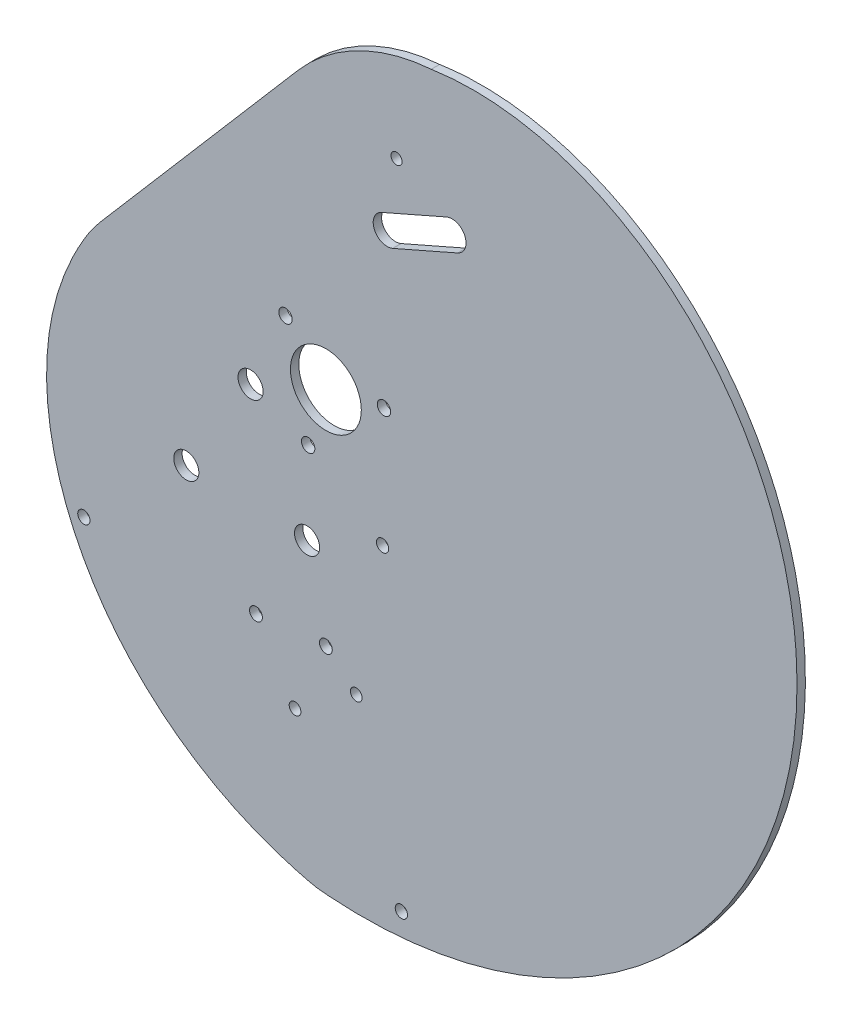
from build123d import *

# Parameters (mm, degrees)
SKETCH1_R               = 6.35
BOSS_EXTRUDE1_DEPTH     = 0.75
CUT_EXTRUDE1_DEPTH      = 102.161590478
CUT_EXTRUDE1_DEPTH_BACK = 102.161590478
FILLET1_R               = 20
BOSS_EXTRUDE2_DEPTH     = 0.75
SKETCH7_R               = 6.35
SKETCH7_R_2             = 3.175
BOSS_EXTRUDE3_DEPTH     = 0.75
SKETCH8_R               = 1
SKETCH8_R_2             = 6.35
CUT_EXTRUDE2_DEPTH      = 116.292862823
CUT_EXTRUDE2_DEPTH_BACK = 116.292862823
M4_CLEARANCE_HOLE1_D    = 4.5
M2_CLEARANCE_HOLE1_D    = 2.4
SKETCH15_R              = 1.1
CUT_EXTRUDE3_DEPTH      = 10
SKETCH16_R              = 1.05
SKETCH16_R_2            = 1.1
CUT_EXTRUDE4_DEPTH      = 116.300180911
SKETCH18_R              = 1.15
CUT_EXTRUDE5_DEPTH      = 116.300180911


with BuildPart() as part:
    # Sketch1 → Boss-Extrude1 (new, symmetric)
    with BuildSketch(Plane.XY):
        with BuildLine():
            ThreePointArc((11.984914181, 27.895733584), (8.691133377, 29.180649151), (9.976048944, 32.474429955))
            Line((9.976048944, 32.474429955), (12.234616167, 33.46535768))
            ThreePointArc((12.234616167, 33.46535768), (8.26006825, 34.969173712), (5.615201844, 38.295308932))
            Line((5.615201844, 38.295308932), (3.856119442, 42.419673356))
            add(Edge.make_bspline(
                [(3.856119442, 42.419673356), (3.804269194, 42.380475154), (3.486745937, 42.138972836), (2.912619563, 41.685826384), (2.149082762, 41.044776761), (1.408732666, 40.385653153), (0.69201842, 39.710962437), (-0.000702823, 39.023274092), (-0.669224606, 38.325164066), (-1.313490613, 37.619209289), (-1.933594741, 36.907981167), (-2.529780734, 36.194039342), (-3.102441662, 35.479925366), (-3.652119172, 34.768156406), (-4.179502537, 34.061218936), (-4.68542751, 33.361562432), (-5.170874981, 32.671593072), (-5.636969475, 31.993667421), (-6.084977486, 31.330086125), (-6.5163057, 30.68308757), (-6.932499191, 30.054841594), (-7.335239472, 29.447442991), (-7.726343211, 28.862905788), (-8.107759261, 28.30315506), (-8.481572996, 27.770028153), (-8.850055929, 27.265150233), (-9.21599154, 26.789707359), (-9.58007402, 26.342396401), (-9.943199031, 25.921274986), (-10.306211946, 25.524302901), (-10.669815304, 25.149428396), (-11.03457423, 24.794597749), (-11.400917427, 24.457759077), (-11.769139802, 24.136868148), (-12.139404915, 23.829894257), (-12.511747444, 23.534826559), (-12.886075425, 23.249680558), (-13.262172288, 22.972504592), (-13.639698706, 22.701386132), (-14.018194373, 22.4344578), (-14.397079826, 22.169903041), (-14.775658393, 21.905961469), (-15.153118349, 21.640933911), (-15.528535328, 21.37318718), (-15.900874865, 21.101158728), (-16.268995598, 20.823360748), (-16.631651048, 20.538385549), (-16.987497448, 20.244905703), (-17.335071725, 19.941700072), (-17.674482118, 19.629485326), (-18.005889299, 19.308945872), (-18.329486913, 18.98074786), (-18.645506177, 18.6455329), (-18.954213469, 18.303917657), (-19.255909475, 17.956492143), (-19.550927855, 17.603818409), (-19.839633983, 17.246429189), (-20.122423608, 16.884826615), (-20.39972148, 16.519480973), (-20.671979932, 16.15082951), (-20.93967742, 15.77927529), (-21.203317027, 15.405186109), (-21.463424922, 15.028893458), (-21.720548787, 14.650691546), (-21.975256201, 14.270836377), (-22.228133, 13.889544888), (-22.479781587, 13.506994147), (-22.730819224, 13.123320602), (-22.981876279, 12.738619403), (-23.233594452, 12.35294377), (-23.486624965, 11.966304432), (-23.741626724, 11.578669117), (-23.999264462, 11.189962103), (-24.260206854, 10.800063825), (-24.52512461, 10.408810538), (-24.794688561, 10.015994037), (-25.069567717, 9.621361426), (-25.350427363, 9.224614974), (-25.637926993, 8.8254119), (-25.932718851, 8.423364715), (-26.235444149, 8.018039723), (-26.546738212, 7.608962846), (-26.867193334, 7.195608336), (-27.197393741, 6.777566684), (-27.537037782, 6.353934602), (-27.885559202, 5.923803469), (-28.242374703, 5.486366009), (-28.606855737, 5.040842301), (-28.978345064, 4.586492757), (-29.356154138, 4.122615768), (-29.739565815, 3.648549546), (-30.127835637, 3.163672741), (-30.520193566, 2.667405334), (-30.915845631, 2.159209384), (-31.313975642, 1.638589743), (-31.713746908, 1.10509472), (-32.114303997, 0.558316687), (-32.514774496, -0.002107372), (-32.914270801, -0.576495363), (-33.311891916, -1.165119646), (-33.70672526, -1.768206653), (-34.097848491, -2.385936568), (-34.484331334, -3.01844306), (-34.865237414, -3.665813085), (-35.239626095, -4.328086735), (-35.606554319, -5.00525716), (-35.965078448, -5.697270543), (-36.314256102, -6.404026134), (-36.653147994, -7.125376348), (-36.98081976, -7.861126926), (-37.296343783, -8.611037148), (-37.598801011, -9.374820113), (-37.887282738, -10.15214308), (-38.160892488, -10.942627847), (-38.418747446, -11.745851279), (-38.659981522, -12.561345551), (-38.883742182, -13.388599746), (-39.089211497, -14.227059816), (-39.27554787, -15.076191303), (-39.442240692, -15.935443066), (-39.58900499, -16.804297383), (-39.715531283, -17.682274795), (-39.821534024, -18.56888584), (-39.906736403, -19.463633732), (-39.970874682, -20.366013757), (-40.01369729, -21.27551381), (-40.034965324, -22.191614638), (-40.034452659, -23.113790166), (-40.011946156, -24.041507803), (-39.967245835, -24.974228766), (-39.900165044, -25.911408403), (-39.810530622, -26.852496518), (-39.698183052, -27.796937709), (-39.56297661, -28.744171699), (-39.4047795, -29.693633681), (-39.223473982, -30.64475466), (-39.018956498, -31.596961802), (-38.791137779, -32.549678783), (-38.539942955, -33.502326148), (-38.265311644, -34.454321664), (-37.967198044, -35.405080681), (-37.645571006, -36.354016496), (-37.300414107, -37.300540716), (-36.931725709, -38.244063627), (-36.539519007, -39.18399456), (-36.123822074, -40.119742265), (-35.684677893, -41.050715279), (-35.222144381, -41.976322302), (-34.736294403, -42.89597257), (-34.227215775, -43.809076229), (-33.695011264, -44.715044715), (-33.139798572, -45.613291121), (-32.561710315, -46.503230581), (-31.960893988, -47.384280643), (-31.337511928, -48.255861642), (-30.69174126, -49.117397078), (-30.023773839, -49.96831399), (-29.333816181, -50.808043326), (-28.622089382, -51.636020317), (-27.888829033, -52.451684847), (-27.134285123, -53.25448182), (-26.358721931, -54.04386153), (-25.562417912, -54.819280022), (-24.745665571, -55.580199454), (-23.908771332, -56.326088459), (-23.052055394, -57.0564225), (-22.175851579, -57.770684224), (-21.280507172, -58.468363812), (-20.366382752, -59.148959324), (-19.433852012, -59.811977048), (-18.483301577, -60.456931829), (-17.515130802, -61.083347415), (-16.529751575, -61.690756781), (-15.527588097, -62.278702456), (-14.50907667, -62.846736843), (-13.474665463, -63.39442255), (-12.424814268, -63.921332635), (-11.359994294, -64.427051169), (-10.280687768, -64.911172569), (-9.187388219, -65.373305515), (-8.080598179, -65.813059652), (-6.960836498, -66.230096831), (-5.828609627, -66.623940268), (-4.684517934, -66.994691537), (-3.528855652, -67.340343195), (-2.3631095, -67.666856553), (-1.184338477, -67.950378607), (-0.400093515, -68.169065005), (0, -68.230921715)],
                knots=[0.595074645, 0.595074645, 0.595074645, 0.595074645, 0.59561552, 0.598394199, 0.601160164, 0.603910525, 0.606641733, 0.609350191, 0.612032273, 0.614684334, 0.617302722, 0.619883791, 0.622423916, 0.624919509, 0.627367038, 0.629763043, 0.632104166, 0.634387177, 0.636609005, 0.638766786, 0.640857908, 0.642880081, 0.644831406, 0.646710483, 0.648516525, 0.650249514, 0.65191136, 0.653508519, 0.655048349, 0.65653798, 0.657984241, 0.659393583, 0.66077201, 0.662125022, 0.663457568, 0.664774018, 0.666078151, 0.667373165, 0.668661696, 0.669945853, 0.671227263, 0.672507127, 0.673786273, 0.67506522, 0.676344239, 0.677623416, 0.678902717, 0.68018205, 0.681461324, 0.682740438, 0.684019262, 0.685297659, 0.686575488, 0.687852615, 0.689128915, 0.690404281, 0.691678632, 0.692951916, 0.694224122, 0.695495279, 0.696765474, 0.698034846, 0.699303605, 0.70057203, 0.70184048, 0.703109399, 0.704379325, 0.705650892, 0.706924838, 0.708202013, 0.709483377, 0.710770009, 0.712063109, 0.713363997, 0.714674119, 0.715995039, 0.717328447, 0.718676146, 0.720040056, 0.721422204, 0.722824718, 0.724249822, 0.725699824, 0.727177002, 0.72868281, 0.730218172, 0.731783831, 0.733380363, 0.735008197, 0.736667628, 0.738358831, 0.740081872, 0.741836722, 0.743623264, 0.745441305, 0.747290584, 0.749170776, 0.751081502, 0.753022336, 0.754992805, 0.756992401, 0.759020578, 0.761076761, 0.763160347, 0.76527071, 0.767407202, 0.769569155, 0.771755887, 0.7739667, 0.776200882, 0.778457713, 0.780736462, 0.783036392, 0.785356757, 0.787696808, 0.790055792, 0.792432952, 0.794827532, 0.797238799, 0.799666426, 0.802110394, 0.804570687, 0.807047284, 0.809540165, 0.812049305, 0.814574675, 0.817116246, 0.819673984, 0.822247852, 0.824837811, 0.82744382, 0.830065834, 0.832703806, 0.835357687, 0.838027424, 0.840712962, 0.843414244, 0.84613121, 0.848863798, 0.851611942, 0.854375576, 0.857154631, 0.859949033, 0.862758708, 0.865583582, 0.868423573, 0.871278601, 0.874148584, 0.877033434, 0.879933066, 0.882847387, 0.885776307, 0.888719732, 0.891677564, 0.894649707, 0.897636058, 0.900636516, 0.903650977, 0.906679333, 0.909721476, 0.912777297, 0.915846682, 0.918929518, 0.922025687, 0.925135072, 0.928257554, 0.931393009, 0.934541315, 0.937702347, 0.940875975, 0.944062073, 0.947260508, 0.950471149, 0.95369386, 0.956928506, 0.960174949, 0.96343305, 0.966702667, 0.969983657, 0.973275876, 0.976579178, 0.979893415, 0.983218438, 0.986554095, 0.989900235, 0.993256703, 0.996623344, 1, 1, 1, 1], degree=3))
            add(Edge.make_bspline(
                [(0, -68.230921715), (0.393333706, -68.291733321), (1.194961176, -68.321276753), (2.388868431, -68.414811628), (3.58891617, -68.470136134), (4.791044831, -68.510535556), (5.995946289, -68.52954927), (7.203026535, -68.528713614), (8.412027616, -68.507423129), (9.62259203, -68.465654591), (10.83437986, -68.403235569), (12.047037443, -68.320041284), (13.260205927, -68.215942066), (14.473519127, -68.090817818), (15.686604264, -67.944554476), (16.899081946, -67.777045295), (18.110566359, -67.588190842), (19.320665416, -67.377899329), (20.528980925, -67.146086849), (21.73510877, -66.892677633), (22.938639087, -66.6176043), (24.139156466, -66.320808097), (25.336240146, -66.002239142), (26.529464226, -65.661856654), (27.718397887, -65.299629187), (28.90260561, -64.915534847), (30.081647414, -64.509561514), (31.255079097, -64.081707052), (32.42245248, -63.631979515), (33.58331567, -63.160397343), (34.737213315, -62.666989561), (35.883686879, -62.151795956), (37.022274916, -61.614867262), (38.152513354, -61.056265327), (39.273935784, -60.476063279), (40.386073758, -59.87434568), (41.488457085, -59.251208675), (42.580614147, -58.606760131), (43.662072205, -57.941119771), (44.732357722, -57.254419292), (45.790996682, -56.546802486), (46.837514925, -55.81842534), (47.871438475, -55.069456136), (48.89229388, -54.300075538), (49.899608554, -53.51047667), (50.892911122, -52.700865183), (51.871731772, -51.87145932), (52.835602603, -51.022489959), (53.784057989, -50.154200657), (54.71663493, -49.26684768), (55.632873421, -48.360700021), (56.532316811, -47.436039411), (57.414512174, -46.493160317), (58.279010671, -45.532369935), (59.125367928, -44.553988165), (59.953144401, -43.558347582), (60.761905749, -42.545793391), (61.55122321, -41.516683378), (62.320673971, -40.471387842), (63.069841543, -39.410289525), (63.798316132, -38.333783527), (64.505695017, -37.242277204), (65.191582915, -36.13619007), (65.85559236, -35.015953676), (66.497344063, -33.882011479), (67.11646729, -32.734818707), (67.71260022, -31.574842209), (68.285390316, -30.402560293), (68.834494677, -29.218462553), (69.359580408, -28.023049692), (69.860324965, -26.816833323), (70.336416512, -25.60033577), (70.787554269, -24.374089852), (71.213448854, -23.13863866), (71.613822626, -21.894535318), (71.988410015, -20.642342743), (72.336957858, -19.382633384), (72.659225719, -18.115988959), (72.954986211, -16.843000179), (73.224025309, -15.564266461), (73.466142659, -14.28039563), (73.681151874, -12.992003617), (73.868880836, -11.699714142), (74.029171977, -10.404158388), (74.161882563, -9.10597467), (74.266884966, -7.805808087), (74.344066927, -6.504310174), (74.393331816, -5.202138538), (74.414598879, -3.89995649), (74.407803478, -2.598432666), (74.372897323, -1.29824064), (74.309848696, -5.853e-05), (74.218642658, 1.295431404), (74.099281259, 2.587543173), (73.95178373, 3.875587471), (73.776186663, 5.158872107), (73.572544188, 6.43670243), (73.340928136, 7.708381771), (73.081428188, 8.973211889), (72.794152019, 10.230493418), (72.47922543, 11.479526328), (72.13679246, 12.719610386), (71.767015501, 13.950045625), (71.37007539, 15.170132817), (70.946171493, 16.379173951), (70.495521777, 17.576472716), (70.018362872, 18.761334989), (69.514950114, 19.933069325), (68.985557583, 21.090987453), (68.430478125, 22.234404772), (67.850023359, 23.362640855), (67.244523678, 24.47501995), (66.614328227, 25.570871489), (65.959804877, 26.649530597), (65.281340181, 27.710338599), (64.579339317, 28.752643533), (63.85422602, 29.775800665), (63.106442497, 30.779173), (62.33644933, 31.762131799), (61.544725366, 32.724057086), (60.731767601, 33.66433818), (59.898090995, 34.582374149), (59.044228508, 35.477574541), (58.170730235, 36.349359075), (57.278166357, 37.197160694), (56.367121668, 38.020410915), (55.438270074, 38.818621759), (54.492318121, 39.591335254), (53.529982536, 40.3381068), (52.551992493, 41.058512637), (51.559087829, 41.752148676), (50.552018856, 42.418631155), (49.531545735, 43.057596786), (48.498437965, 43.668703015), (47.453473832, 44.251628246), (46.397439863, 44.806072049), (45.331130274, 45.331755356), (44.255346411, 45.828420647), (43.17089619, 46.295832116), (42.078593533, 46.733775825), (40.979257798, 47.142059848), (39.873713209, 47.520514394), (38.762788284, 47.868991924), (37.647315256, 48.187367242), (36.528129497, 48.475537585), (35.406068937, 48.733422689), (34.281973488, 48.960964845), (33.156684455, 49.158128938), (32.031043959, 49.324902476), (30.905894352, 49.461295599), (29.78207764, 49.567341079), (28.66043489, 49.643094299), (27.541805663, 49.688633226), (26.427027423, 49.704058363), (25.316934962, 49.689492689), (24.212359828, 49.645081585), (23.114129743, 49.570992746), (22.023068037, 49.46741608), (20.939993076, 49.334563587), (19.865717696, 49.172669234), (19.050939925, 49.026743912), (18.594215776, 48.936446476), (18.491236259, 48.915651329)],
                knots=[0, 0, 0, 0, 0.003319606, 0.00664483, 0.00997572, 0.013312315, 0.016654652, 0.020002764, 0.023356679, 0.026716422, 0.030082012, 0.033453467, 0.036830797, 0.040214011, 0.043603114, 0.046998106, 0.050398984, 0.05380574, 0.057218364, 0.060636841, 0.064061153, 0.067491279, 0.070927192, 0.074368865, 0.077816264, 0.081269354, 0.084728096, 0.088192446, 0.09166236, 0.095137787, 0.098618675, 0.102104968, 0.105596607, 0.10909353, 0.112595671, 0.116102963, 0.119615332, 0.123132706, 0.126655005, 0.130182149, 0.133714056, 0.137250637, 0.140791804, 0.144337465, 0.147887524, 0.151441884, 0.155000443, 0.158563099, 0.162129745, 0.165700272, 0.169274569, 0.172852522, 0.176434014, 0.180018926, 0.183607137, 0.187198521, 0.190792953, 0.194390304, 0.197990441, 0.201593231, 0.205198539, 0.208806224, 0.212416148, 0.216028167, 0.219642135, 0.223257906, 0.226875331, 0.230494258, 0.234114533, 0.237736001, 0.241358506, 0.244981886, 0.248605983, 0.252230632, 0.255855669, 0.259480928, 0.263106241, 0.266731437, 0.270356345, 0.273980794, 0.277604607, 0.281227611, 0.284849627, 0.288470478, 0.292089983, 0.295707963, 0.299324234, 0.302938615, 0.306550921, 0.310160967, 0.313768569, 0.317373538, 0.320975689, 0.324574833, 0.328170782, 0.331763348, 0.335352341, 0.338937573, 0.342518853, 0.346095993, 0.349668803, 0.353237093, 0.356800674, 0.360359359, 0.363912958, 0.367461284, 0.37100415, 0.37454137, 0.37807276, 0.381598135, 0.385117313, 0.388630113, 0.392136355, 0.395635862, 0.399128458, 0.402613969, 0.406092224, 0.409563054, 0.413026294, 0.416481778, 0.419929348, 0.423368847, 0.426800121, 0.43022302, 0.4336374, 0.437043112, 0.440439966, 0.443827754, 0.447206268, 0.450575308, 0.453934675, 0.457284173, 0.460623612, 0.463952804, 0.467271567, 0.470579721, 0.473877092, 0.477163509, 0.480438807, 0.483702825, 0.486955407, 0.490196401, 0.493425661, 0.496643048, 0.499848424, 0.50304166, 0.506222633, 0.509391223, 0.512547319, 0.515690814, 0.518821608, 0.521939609, 0.52504473, 0.528136891, 0.531216019, 0.53428205, 0.537334925, 0.540374595, 0.543401017, 0.546414157, 0.549413988, 0.550288202, 0.550288202, 0.550288202, 0.550288202], degree=3))
            Line((18.491236259, 48.915651329), (20.341962163, 44.576418519))
            ThreePointArc((20.341962163, 44.576418519), (20.922430656, 40.447066292), (19.347370503, 36.586019931))
            Line((19.347370503, 36.586019931), (21.605937727, 37.576947657))
            ThreePointArc((21.605937727, 37.576947657), (24.899718531, 36.29203209), (23.614802964, 32.998251286))
            Line((23.614802964, 32.998251286), (11.984914181, 27.895733584))
        make_face()
        Circle(SKETCH1_R, mode=Mode.SUBTRACT)
    extrude(amount=BOSS_EXTRUDE1_DEPTH, both=True)

    # Sketch2 → Cut-Extrude1 (cut, two sides)
    with BuildSketch(Plane.XY) as cut_extrude1_sk:
        Polygon((-35.700141367, -3.650772794), (-7.072677907, 43.311946145), (4.622228263, 43.311946145), (7.657062795, 40.706225638), (-41.200196706, -16.19692185), align=None)
    extrude(amount=CUT_EXTRUDE1_DEPTH, mode=Mode.SUBTRACT)
    extrude(cut_extrude1_sk.sketch, amount=-CUT_EXTRUDE1_DEPTH_BACK, mode=Mode.SUBTRACT)

    # Fillet1
    fillet1_edges = [part.edges().sort_by_distance(p)[0] for p in [
        (-38.918855467, -13.539885857, -0.3749997),
    ]]
    fillet(fillet1_edges, radius=FILLET1_R)

    # Sketch6 → Boss-Extrude2 (add, symmetric)
    with BuildSketch(Plane.XY):
        with BuildLine():
            Line((-40.240877686, 5.985028621), (-5.010941183, 47.016684781))
            ThreePointArc((-5.010941183, 47.016684781), (5.728997706, 55.445724795), (18.87378975, 59.134822925))
            add(Edge.make_bspline(
                [(18.87378975, 59.134822925), (22.516816499, 59.686781934), (26.193665623, 59.826089241), (33.45068059, 59.346128102), (37.03127521, 58.727162925), (43.967380955, 56.811462619), (47.322941455, 55.514954983), (53.707777021, 52.33122275), (56.737127918, 50.44408812), (62.389510018, 46.169164114), (65.013399799, 43.779091446), (69.784563311, 38.606399125), (71.934248393, 35.823640098), (75.732728508, 29.964309697), (77.38163003, 26.887763022), (80.164369364, 20.532587656), (81.298305727, 17.253908281), (83.048505582, 10.579036383), (83.664794752, 7.182960151), (84.3865512, 0.351701111), (84.49206067, -3.083543307), (84.207163067, -9.921041673), (83.816786418, -13.323289058), (82.562035426, -20.02858371), (81.697681537, -23.331653399), (78.43581289, -33.001341548), (75.366981688, -39.125760708), (67.729460455, -50.317148913), (63.161306968, -55.384041979), (52.884055324, -64.145782257), (47.175773764, -67.840270189), (35.026492532, -73.650102546), (28.586660871, -75.765074216), (18.701604185, -77.686070484), (15.369124025, -78.118771701), (10.354347453, -78.456714462), (8.679694279, -78.517619619), (6.587494274, -78.529369489), (6.170144087, -78.528514895), (5.334254192, -78.520512469), (4.913726597, -78.513297138), (4.071953989, -78.491958341), (3.658588776, -78.478091881), (3.049726248, -78.454186132), (2.84322124, -78.445541202), (2.413523355, -78.425490471), (2.191852793, -78.414139452), (1.849187473, -78.394199653), (1.730797282, -78.386869887), (1.509810446, -78.372493071), (1.405806762, -78.365417657), (1.113185905, -78.345280212), (0.943966862, -78.333383035), (0.764379497, -78.321776976), (0.73005815, -78.319613099), (0.664594577, -78.315610277), (0.63534896, -78.313880378), (0.539106387, -78.308417555), (0.45074868, -78.303757443), (0.113509584, -78.284976779), (-0.207625858, -78.267133918), (-0.83334031, -78.206206545), (-1.065924997, -78.179928196), (-1.449875604, -78.125911632), (-1.586886359, -78.10482735), (-1.843429138, -78.061893669), (-1.9656288, -78.039781678), (-2.546485276, -77.928478506), (-2.914665113, -77.838372208), (-3.330367332, -77.733106974), (-3.446176837, -77.702738066), (-3.586243748, -77.666027804), (-3.627318292, -77.655250883), (-3.698237511, -77.636744195), (-3.727677684, -77.629118622), (-3.894219178, -77.586307455), (-4.209129691, -77.507522483), (-4.621197785, -77.404374047), (-4.966045453, -77.314890963), (-5.081761547, -77.284340829), (-5.307399032, -77.223863613), (-5.640671054, -77.133177129), (-5.958569588, -77.043301816), (-6.3690401, -76.92534283), (-6.569336345, -76.86688301), (-7.182238051, -76.685143344), (-7.599606088, -76.557325569), (-8.429873477, -76.293278955), (-8.841288901, -76.157777564), (-10.890638145, -75.460646132), (-12.514573758, -74.835436277), (-15.706026772, -73.455756722), (-17.275815259, -72.700597027), (-21.890382607, -70.242328218), (-24.840585086, -68.345949758), (-30.394739385, -64.064839156), (-32.998609007, -61.680083928), (-37.761620342, -56.464319213), (-39.920617277, -53.633310877), (-43.690890371, -47.586553566), (-45.302087265, -44.370646153), (-47.870223233, -37.640179849), (-48.827104768, -34.12524618), (-49.978597119, -26.91435666), (-50.172989153, -23.218002666), (-49.813728375, -17.658491884), (-49.585534592, -15.803221116), (-49.071422005, -13.036209995), (-48.870846793, -12.115044492), (-48.414877231, -10.293400604), (-48.159605564, -9.392104476), (-47.316449698, -6.721187383), (-46.650942966, -4.984635667), (-45.143678718, -1.623776037), (-44.301508679, 0.000832802), (-43.392795008, 1.558582512)],
                knots=[0, 0, 0, 0, 0.03125, 0.03125, 0.0625, 0.0625, 0.09375, 0.09375, 0.125, 0.125, 0.15625, 0.15625, 0.1875, 0.1875, 0.21875, 0.21875, 0.25, 0.25, 0.28125, 0.28125, 0.3125, 0.3125, 0.34375, 0.34375, 0.375, 0.375, 0.4375, 0.4375, 0.5, 0.5, 0.5625, 0.5625, 0.625, 0.625, 0.65625, 0.65625, 0.671875, 0.671875, 0.67578125, 0.67578125, 0.6796875, 0.6796875, 0.68359375, 0.68359375, 0.685546875, 0.685546875, 0.6875, 0.6875, 0.688476562, 0.688476562, 0.689453125, 0.689453125, 0.69140625, 0.69140625, 0.691894531, 0.691894531, 0.692382812, 0.692382812, 0.693359375, 0.693359375, 0.6953125, 0.6953125, 0.696289062, 0.696289062, 0.696777344, 0.696777344, 0.697265625, 0.697265625, 0.69921875, 0.69921875, 0.700195312, 0.700195312, 0.700683594, 0.700683594, 0.701171875, 0.701171875, 0.703125, 0.705078125, 0.705078125, 0.706054687, 0.706054687, 0.70703125, 0.708984375, 0.708984375, 0.7109375, 0.7109375, 0.71484375, 0.71484375, 0.71875, 0.71875, 0.734375, 0.734375, 0.75, 0.75, 0.78125, 0.78125, 0.8125, 0.8125, 0.84375, 0.84375, 0.875, 0.875, 0.90625, 0.90625, 0.9375, 0.9375, 0.953125, 0.953125, 0.9609375, 0.9609375, 0.96875, 0.96875, 0.984375, 0.984375, 1, 1, 1, 1], degree=3))
            ThreePointArc((-43.392795008, 1.558582512), (-41.917264231, 3.843316747), (-40.240877686, 5.985028621))
        make_face()
    extrude(amount=BOSS_EXTRUDE2_DEPTH, both=True)

    # Sketch7 → Boss-Extrude3 (add, symmetric)
    with BuildSketch(Plane.XY):
        Circle(SKETCH7_R)
        Circle(SKETCH7_R_2, mode=Mode.SUBTRACT)
    extrude(amount=BOSS_EXTRUDE3_DEPTH, both=True)

    # Sketch8 → Cut-Extrude2 (cut, two sides)
    with BuildSketch(Plane.XY) as cut_extrude2_sk:
        with Locations((12.655385599, 42.167672501)):
            Circle(SKETCH8_R)
        Circle(SKETCH8_R_2)
        with BuildLine():
            Line((9.976048944, 32.474429955), (21.605937727, 37.576947657))
            ThreePointArc((21.605937727, 37.576947657), (24.899718531, 36.29203209), (23.614802964, 32.998251286))
            Line((23.614802964, 32.998251286), (11.984914181, 27.895733584))
            ThreePointArc((11.984914181, 27.895733584), (8.691133377, 29.180649151), (9.976048944, 32.474429955))
        make_face()
    extrude(amount=CUT_EXTRUDE2_DEPTH, mode=Mode.SUBTRACT)
    extrude(cut_extrude2_sk.sketch, amount=-CUT_EXTRUDE2_DEPTH_BACK, mode=Mode.SUBTRACT)

    # M4 Clearance Hole1 (through all)
    with Locations(Plane.XY.offset(0.75)):
        with Locations((-13.488047982, -5.9360377), (-3.367538379, -25.076378767), (-25.003814781, -24.270826649)):
            Hole(M4_CLEARANCE_HOLE1_D / 2)

    # M2 Clearance Hole1 (through all)
    with Locations(Plane(origin=(0, 0, -0.75), x_dir=(-1, 0, 0), z_dir=(0, 0, -1))):
        with Locations((7.233951111, 7.840674418), (3.173247673, -10.185122641), (-10.407198784, 2.344448223)):
            Hole(M2_CLEARANCE_HOLE1_D / 2)

    # Sketch15 → Cut-Extrude3 (cut)
    with BuildSketch(Plane.XY.offset(0.75)):
        with Locations((-43.353129439, -41.45965752)):
            Circle(SKETCH15_R)
        with Locations((13.526187427, -74.200894977)):
            Circle(SKETCH15_R)
    extrude(amount=-CUT_EXTRUDE3_DEPTH, mode=Mode.SUBTRACT)

    # Sketch16 → Cut-Extrude4 (cut, through all)
    with BuildSketch(Plane.XY.offset(0.75)):
        with Locations((-5.52301951, -52.247407725)):
            Circle(SKETCH16_R)
        with Locations((5.444897507, -44.593507485)):
            Circle(SKETCH16_R)
        with Locations((10.161083996, -19.103509841)):
            Circle(SKETCH16_R_2)
    extrude(amount=-CUT_EXTRUDE4_DEPTH, mode=Mode.SUBTRACT)

    # Sketch18 → Cut-Extrude5 (cut, through all)
    with BuildSketch(Plane.XY.offset(0.75)):
        with Locations((-12.52460351, -41.04915847)):
            Circle(SKETCH18_R)
        with Locations((0, -39.8190457)):
            Circle(SKETCH18_R)
    extrude(amount=-CUT_EXTRUDE5_DEPTH, mode=Mode.SUBTRACT)


solid = part.part
